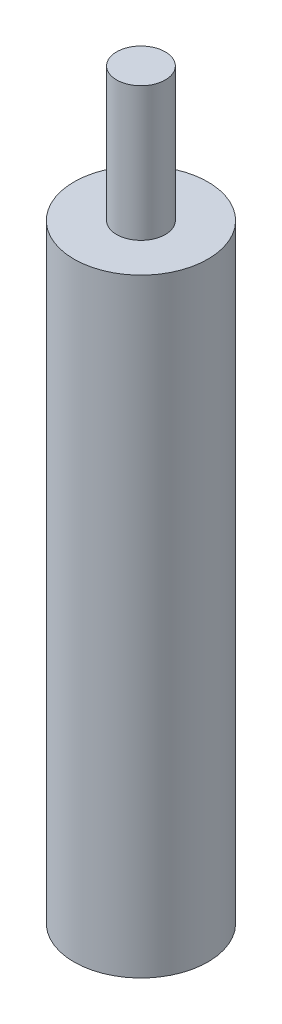
from build123d import *

# Parameters (mm, degrees)
ESQUISSE1_R             = 5.5
BOSS_EXTRU_1_DEPTH      = 50
ESQUISSE2_R             = 2
BOSS_EXTRU_2_DEPTH      = 11
ESQUISSE3_R             = 2
ENL_V_MAT_EXTRU_1_DEPTH = 11


with BuildPart() as part:
    # Esquisse1 → Boss.-Extru.1 (new body)
    with BuildSketch(Plane(origin=(0, 0, 0), x_dir=(1, 0, 0), z_dir=(0, 1, 0))):
        Circle(ESQUISSE1_R)
    extrude(amount=BOSS_EXTRU_1_DEPTH)

    # Esquisse2 → Boss.-Extru.2 (add)
    with BuildSketch(Plane(origin=(0, 50, 0), x_dir=(1, 0, 0), z_dir=(0, 1, 0))):
        Circle(ESQUISSE2_R)
    extrude(amount=BOSS_EXTRU_2_DEPTH)

    # Esquisse3 → Enlèv. mat.-Extru.1 (cut)
    with BuildSketch(Plane.XZ):
        Circle(ESQUISSE3_R)
    extrude(amount=-ENL_V_MAT_EXTRU_1_DEPTH, mode=Mode.SUBTRACT)


solid = part.part
